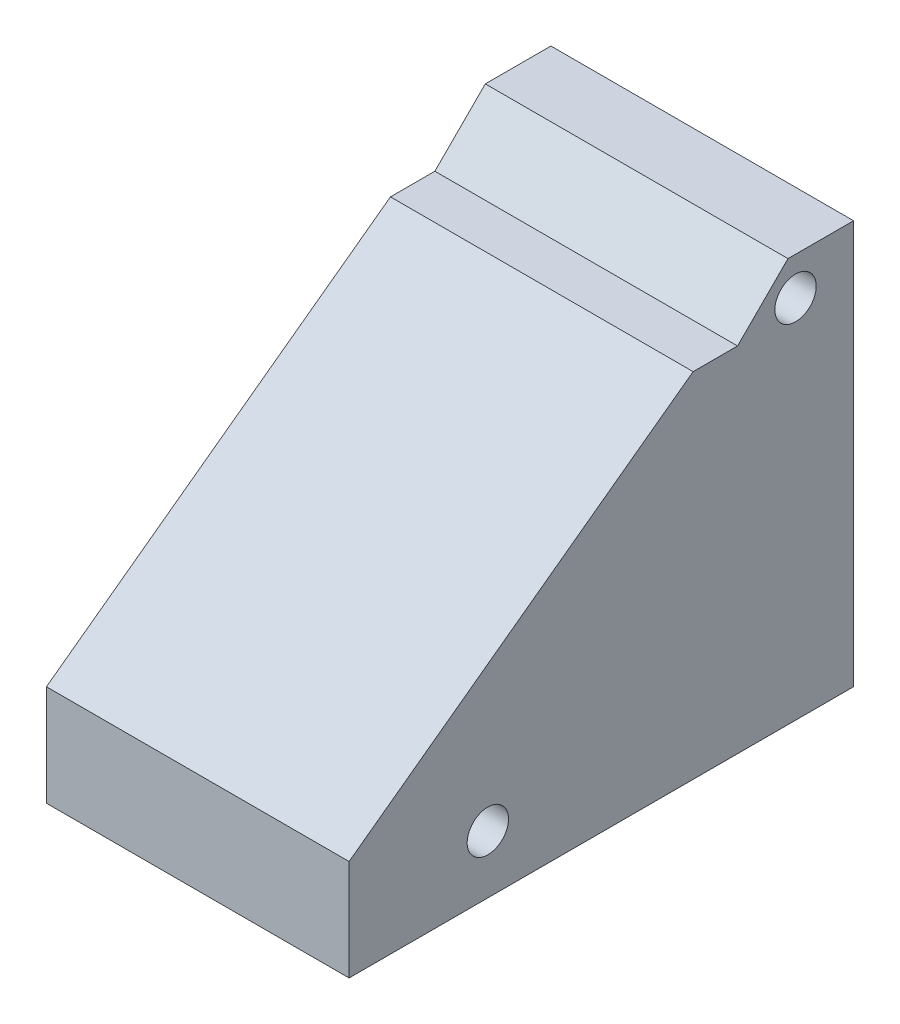
from build123d import *

# Parameters (mm, degrees)
SKETCH1_R           = 4.1
BOSS_EXTRUDE1_DEPTH = 60


with BuildPart() as part:
    # Sketch1 → Boss-Extrude1 (new body)
    with BuildSketch(Plane(origin=(0, 0, 0), x_dir=(0, 0, -1), z_dir=(1, 0, 0))):
        Polygon((0, 0), (-100, 0), (-100, 20), (-31.805308068, 70.001510114), (-22.998489886, 70.001510114), (-13, 80), (0, 80), align=None)
        with Locations((-11.5, 72.5)):
            Circle(SKETCH1_R, mode=Mode.SUBTRACT)
        with Locations((-72.5, 11.5)):
            Circle(SKETCH1_R, mode=Mode.SUBTRACT)
    extrude(amount=BOSS_EXTRUDE1_DEPTH)


solid = part.part
